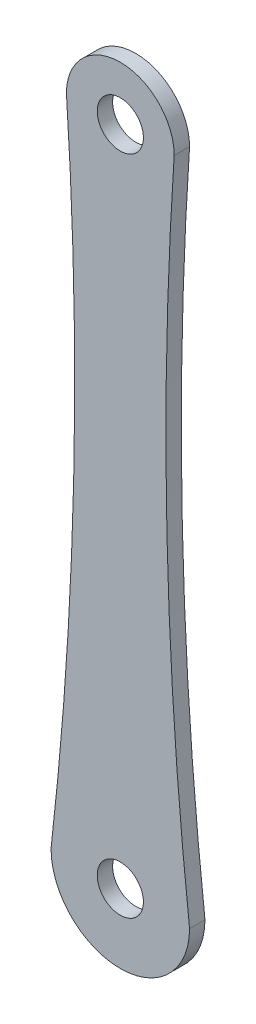
from build123d import *

# Parameters (mm, degrees)
CROQUIS2_R              = 1.5
SALIENTE_EXTRUIR1_DEPTH = 1
ESCALA1_SCALE           = 7


with BuildPart() as part:
    # Croquis2 → Saliente-Extruir1 (new body)
    with BuildSketch(Plane.XY):
        with BuildLine():
            ThreePointArc((3.5, 47.5), (0, 51), (-3.5, 47.5))
            ThreePointArc((-3.5, 47.5), (-3.029104107, 25.977421026), (-4.5, 4.5))
            ThreePointArc((-4.5, 4.5), (0, 0), (4.5, 4.5))
            ThreePointArc((4.5, 4.5), (3.029104107, 25.977421026), (3.5, 47.5))
        make_face()
        with Locations((0, 47.5)):
            Circle(CROQUIS2_R, mode=Mode.SUBTRACT)
        with Locations((0, 4.5)):
            Circle(CROQUIS2_R, mode=Mode.SUBTRACT)
    extrude(amount=SALIENTE_EXTRUIR1_DEPTH)


with BuildPart() as part_1:
    # Escala1: scaled about (0, 24.124187823, 0.5)
    add(part.part.scale(ESCALA1_SCALE).moved(Location((0, -144.745126938, -3))))


solid = part_1.part
